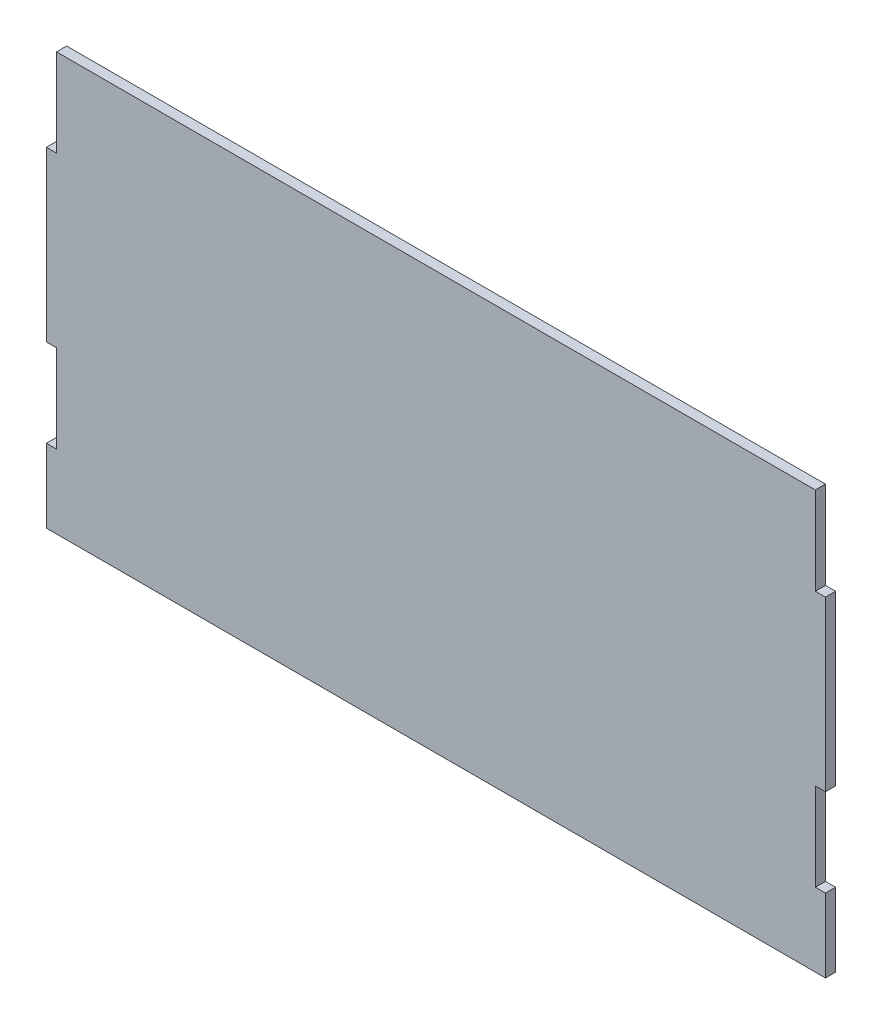
from build123d import *

# Parameters (mm, degrees)
BOSS_EXTRUDE1_DEPTH = 3


with BuildPart() as part:
    # Sketch1 → Boss-Extrude1 (new body)
    with BuildSketch(Plane.XY):
        Polygon((-112.34268018, 49.584121622), (-112.34268018, 23.584121622), (-115.34268018, 23.584121622), (-115.34268018, -26.415878378), (-112.34268018, -26.415878378), (-112.34268018, -52.415878378), (-115.34268018, -52.415878378), (-115.34268018, -74.225878378), (115.65731982, -74.225878378), (115.65731982, -52.415878378), (112.65731982, -52.415878378), (112.65731982, -26.415878378), (115.65731982, -26.415878378), (115.65731982, 23.584121622), (112.65731982, 23.584121622), (112.65731982, 49.584121622), align=None)
    extrude(amount=BOSS_EXTRUDE1_DEPTH)


solid = part.part
